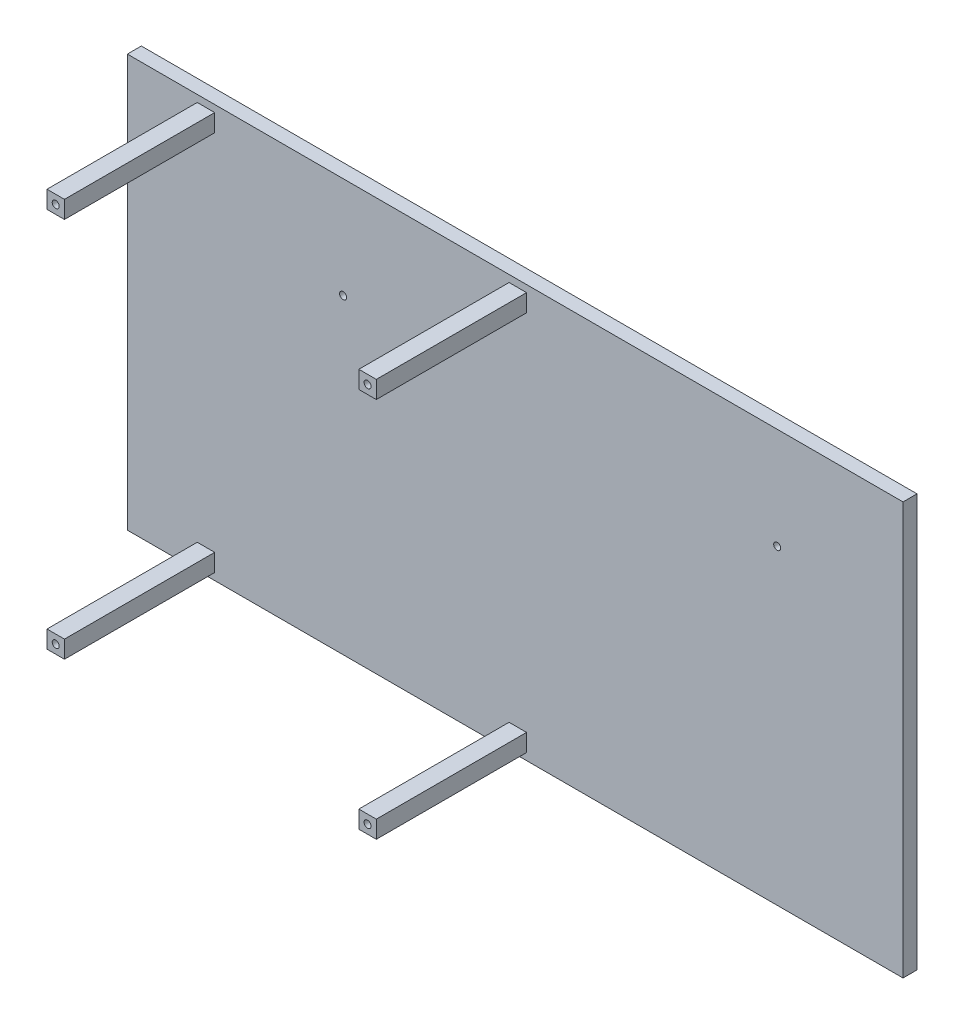
from build123d import *

# Parameters (mm, degrees)
SKETCH1_W            = 200
SKETCH1_H            = 150
BOSS_EXTRUDE1_DEPTH  = 4
SKETCH2_W            = 4
SKETCH2_H            = 150
BOSS_EXTRUDE2_DEPTH  = 50
SKETCH3_R            = 1
CUT_EXTRUDE1_DEPTH   = 21
SKETCH4_R            = 1
CUT_EXTRUDE2_DEPTH   = 21
SKETCH5_R            = 1
CUT_EXTRUDE3_DEPTH   = 21
SKETCH6_R            = 1
CUT_EXTRUDE4_DEPTH   = 5
SKETCH7_R            = 6.144102529
BOSS_EXTRUDE3_DEPTH  = 4
SKETCH8_W            = 5
SKETCH8_H            = 5
BOSS_EXTRUDE4_DEPTH  = 43
SKETCH9_W            = 5
SKETCH9_H            = 5
BOSS_EXTRUDE5_DEPTH  = 43
SKETCH10_W           = 5
SKETCH10_H           = 5
BOSS_EXTRUDE6_DEPTH  = 43
SKETCH11_W           = 30
SKETCH11_H           = 150
CUT_EXTRUDE5_DEPTH   = 10
SKETCH12_W           = 220
SKETCH12_H           = 24.5
CUT_EXTRUDE6_DEPTH   = 10
SKETCH13_W           = 40.875499452
SKETCH13_H           = 23.792139599
SKETCH13_W_2         = 30.776846646
SKETCH13_H_2         = 32.17722556
CUT_EXTRUDE7_DEPTH   = 43
SKETCH14_W           = 220
SKETCH14_H           = 7.5
CUT_EXTRUDE8_DEPTH   = 10
SKETCH15_W           = 2
SKETCH15_H           = 118
BOSS_EXTRUDE7_DEPTH  = 47
SKETCH17_W           = 7
SKETCH17_H           = 7
BOSS_EXTRUDE8_DEPTH  = 10
SKETCH18_R           = 2.5
CUT_EXTRUDE9_DEPTH   = 9
SKETCH19_R           = 1
BOSS_EXTRUDE9_DEPTH  = 9
FILLET1_R            = 1
SKETCH20_W           = 7.2
SKETCH20_H           = 14.5
BOSS_EXTRUDE10_DEPTH = 10
SKETCH21_W           = 4.962321038
SKETCH21_H           = 12.373907849
CUT_EXTRUDE10_DEPTH  = 9
SKETCH22_W           = 0.777431132
SKETCH22_H           = 9.230205418
BOSS_EXTRUDE11_DEPTH = 8
SKETCH23_W           = 0.590875022
SKETCH23_H           = 0.8
SKETCH23_H_2         = 0.836280482
SKETCH23_H_3         = 0.787087512
BOSS_EXTRUDE12_DEPTH = 7
SKETCH24_W           = 5
SKETCH24_H           = 5
BOSS_EXTRUDE13_DEPTH = 43
SKETCH25_W           = 5
SKETCH25_H           = 5
BOSS_EXTRUDE14_DEPTH = 43
CUT_EXTRUDE11_START  = -43
SKETCH26_W           = 5
SKETCH26_H           = 5
CUT_EXTRUDE11_DEPTH  = 43
SKETCH27_W           = 5
SKETCH27_H           = 5
BOSS_EXTRUDE15_DEPTH = 43
CUT_EXTRUDE12_START  = -43
SKETCH28_W           = 5
SKETCH28_H           = 5
CUT_EXTRUDE12_DEPTH  = 43
SKETCH29_W           = 2
SKETCH29_H           = 66.409922273
BOSS_EXTRUDE16_DEPTH = 47
SKETCH30_W           = 8
SKETCH30_H           = 7
SKETCH30_H_2         = 14.5
CUT_EXTRUDE13_DEPTH  = 9.5
SKETCH31_W           = 5
SKETCH31_H           = 5
CUT_EXTRUDE14_DEPTH  = 43
SKETCH32_W           = 5
SKETCH32_H           = 5
BOSS_EXTRUDE17_DEPTH = 43
SKETCH35_W           = 5
SKETCH35_H           = 5
BOSS_EXTRUDE18_DEPTH = 43
SKETCH37_R           = 1
CUT_EXTRUDE16_DEPTH  = 3
CUT_EXTRUDE17_START  = -43
SKETCH38_W           = 2
SKETCH38_H           = 118
CUT_EXTRUDE17_DEPTH  = 43
SKETCH39_W           = 5
SKETCH39_H           = 5
BOSS_EXTRUDE19_DEPTH = 43
CUT_EXTRUDE18_START  = -43
SKETCH40_W           = 5
SKETCH40_H           = 5
CUT_EXTRUDE18_DEPTH  = 43
SKETCH41_R           = 1
CUT_EXTRUDE19_DEPTH  = 3
CUT_EXTRUDE20_START  = -43
SKETCH42_W           = 21.919538156
SKETCH42_H           = 26.204036761
CUT_EXTRUDE20_DEPTH  = 43
SKETCH43_W           = 59.077186418
SKETCH43_H           = 35.909235562
BOSS_EXTRUDE20_DEPTH = 4


with BuildPart() as part:
    # Sketch1 → Boss-Extrude1 (new body)
    with BuildSketch(Plane.XY):
        with Locations((0.223214286, -36.941964286)):
            Rectangle(SKETCH1_W, SKETCH1_H)
    extrude(amount=BOSS_EXTRUDE1_DEPTH)

    # Sketch2 → Boss-Extrude2 (add)
    with BuildSketch(Plane(origin=(100.223214286, 0, 0), x_dir=(0, 0, -1), z_dir=(1, 0, 0))):
        with Locations((-2, -36.941964286)):
            Rectangle(SKETCH2_W, SKETCH2_H)
    extrude(amount=BOSS_EXTRUDE2_DEPTH)

    # Sketch3 → Cut-Extrude1 (cut)
    with BuildSketch(Plane(origin=(0, 0, 0), x_dir=(-1, 0, 0), z_dir=(0, 0, -1))):
        with Locations((96.776785714, -77.941964286)):
            Circle(SKETCH3_R)
    extrude(amount=-CUT_EXTRUDE1_DEPTH, mode=Mode.SUBTRACT)

    # Sketch4 → Cut-Extrude2 (cut)
    with BuildSketch(Plane(origin=(0, 0, 0), x_dir=(-1, 0, 0), z_dir=(0, 0, -1))):
        with Locations((-147.223214286, -77.941964286)):
            Circle(SKETCH4_R)
    extrude(amount=-CUT_EXTRUDE2_DEPTH, mode=Mode.SUBTRACT)

    # Sketch5 → Cut-Extrude3 (cut)
    with BuildSketch(Plane(origin=(0, 0, 0), x_dir=(-1, 0, 0), z_dir=(0, 0, -1))):
        with Locations((-99.423214286, -77.941964286)):
            Circle(SKETCH5_R)
    extrude(amount=-CUT_EXTRUDE3_DEPTH, mode=Mode.SUBTRACT)

    # Sketch6 → Cut-Extrude4 (cut, through all)
    with BuildSketch(Plane.XY.offset(4)):
        with Locations((114.203214286, -15.441964286)):
            Circle(SKETCH6_R)
        with Locations((-10.026785714, -15.441964286)):
            Circle(SKETCH6_R)
    extrude(amount=-CUT_EXTRUDE4_DEPTH, mode=Mode.SUBTRACT)

    # Sketch7 → Boss-Extrude3 (add)
    with BuildSketch(Plane(origin=(0, 0, 0), x_dir=(-1, 0, 0), z_dir=(0, 0, -1))):
        with Locations((93.632683185, -80.249228077)):
            Circle(SKETCH7_R)
    extrude(amount=-BOSS_EXTRUDE3_DEPTH)

    # Sketch8 → Boss-Extrude4 (add)
    with BuildSketch(Plane.XY.offset(4)):
        with Locations((-10.026785714, 9.058035714)):
            Rectangle(SKETCH8_W, SKETCH8_H)
        with Locations((113.836980241, 9.058035714)):
            Rectangle(SKETCH8_W, SKETCH8_H)
    extrude(amount=BOSS_EXTRUDE4_DEPTH)

    # Sketch9 → Boss-Extrude5 (add)
    with BuildSketch(Plane.XY.offset(4)):
        with Locations((39.973214286, 9.058035714)):
            Rectangle(SKETCH9_W, SKETCH9_H)
    extrude(amount=BOSS_EXTRUDE5_DEPTH)

    # Sketch10 → Boss-Extrude6 (add)
    with BuildSketch(Plane.XY.offset(4)):
        with Locations((-65.026785714, 9.058035714)):
            Rectangle(SKETCH10_W, SKETCH10_H)
    extrude(amount=BOSS_EXTRUDE6_DEPTH)

    # Sketch11 → Cut-Extrude5 (cut)
    with BuildSketch(Plane.XY.offset(4)):
        with Locations((-84.776785714, -36.941964286)):
            Rectangle(SKETCH11_W, SKETCH11_H)
    extrude(amount=-CUT_EXTRUDE5_DEPTH, mode=Mode.SUBTRACT)

    # Sketch12 → Cut-Extrude6 (cut)
    with BuildSketch(Plane.XY.offset(4)):
        with Locations((40.223214286, 25.808035714)):
            Rectangle(SKETCH12_W, SKETCH12_H)
    extrude(amount=-CUT_EXTRUDE6_DEPTH, mode=Mode.SUBTRACT)

    # Sketch13 → Cut-Extrude7 (cut)
    with BuildSketch(Plane.XY.offset(47)):
        with Locations((121.493324961, 1.661965914)):
            Rectangle(SKETCH13_W, SKETCH13_H)
        with Locations((-5.461167455, 0)):
            Rectangle(SKETCH13_W_2, SKETCH13_H_2)
    extrude(amount=-CUT_EXTRUDE7_DEPTH, mode=Mode.SUBTRACT)

    # Sketch14 → Cut-Extrude8 (cut)
    with BuildSketch(Plane.XY.offset(4)):
        with Locations((40.223214286, -108.191964286)):
            Rectangle(SKETCH14_W, SKETCH14_H)
    extrude(amount=-CUT_EXTRUDE8_DEPTH, mode=Mode.SUBTRACT)

    # Sketch15 → Boss-Extrude7 (add)
    with BuildSketch(Plane(origin=(0, 0, 0), x_dir=(-1, 0, 0), z_dir=(0, 0, -1))):
        with Locations((70.776785714, -45.441964286)):
            Rectangle(SKETCH15_W, SKETCH15_H)
    extrude(amount=-BOSS_EXTRUDE7_DEPTH)

    # Sketch17 → Boss-Extrude8 (add)
    with BuildSketch(Plane.ZY.offset(71.776785714)):
        with Locations((10, -45.441964286)):
            Rectangle(SKETCH17_W, SKETCH17_H)
    extrude(amount=-BOSS_EXTRUDE8_DEPTH)

    # Sketch18 → Cut-Extrude9 (cut)
    with BuildSketch(Plane.ZY.offset(71.776785714)):
        with Locations((10, -45.441964286)):
            Circle(SKETCH18_R)
    extrude(amount=-CUT_EXTRUDE9_DEPTH, mode=Mode.SUBTRACT)

    # Sketch20 → Boss-Extrude10 (add)
    with BuildSketch(Plane.ZY.offset(71.776785714)):
        with Locations((9.71931332, -90.191964286)):
            Rectangle(SKETCH20_W, SKETCH20_H)
    extrude(amount=-BOSS_EXTRUDE10_DEPTH)

    # Sketch21 → Cut-Extrude10 (cut)
    with BuildSketch(Plane.ZY.offset(71.776785714)):
        with Locations((9.788933034, -90.191964286)):
            Rectangle(SKETCH21_W, SKETCH21_H)
    extrude(amount=-CUT_EXTRUDE10_DEPTH, mode=Mode.SUBTRACT)

    # Sketch22 → Boss-Extrude11 (add)
    with BuildSketch(Plane.ZY.offset(62.776785714)):
        with Locations((9.788933034, -90.191964286)):
            Rectangle(SKETCH22_W, SKETCH22_H)
    extrude(amount=BOSS_EXTRUDE11_DEPTH)

    # Sketch23 → Boss-Extrude12 (add)
    with BuildSketch(Plane.ZY.offset(62.776785714)):
        with Locations((10.473086111, -86.324413604)):
            Rectangle(SKETCH23_W, SKETCH23_H)
        with Locations((10.473086111, -88.407696998)):
            Rectangle(SKETCH23_W, SKETCH23_H_2)
        with Locations((10.473086111, -91.482257593)):
            Rectangle(SKETCH23_W, SKETCH23_H_3)
        with Locations((10.473086111, -93.720537707)):
            Rectangle(SKETCH23_W, SKETCH23_H_2)
    extrude(amount=BOSS_EXTRUDE12_DEPTH)

    # Sketch24 → Boss-Extrude13 (add)
    with BuildSketch(Plane.XY.offset(4)):
        with Locations((39.973214286, -39.941964286)):
            Rectangle(SKETCH24_W, SKETCH24_H)
    extrude(amount=BOSS_EXTRUDE13_DEPTH)

    # Sketch25 → Boss-Extrude14 (add)
    with BuildSketch(Plane.XY.offset(4)):
        with Locations((39.973214286, -65.941964286)):
            Rectangle(SKETCH25_W, SKETCH25_H)
        with Locations((-65.026785714, -65.941964286)):
            Rectangle(SKETCH25_W, SKETCH25_H)
    extrude(amount=BOSS_EXTRUDE14_DEPTH)

    # Sketch26 → Cut-Extrude11 (cut)
    with BuildSketch(Plane.XY.offset(47).offset(CUT_EXTRUDE11_START)):
        with Locations((39.973214286, -39.941964286)):
            Rectangle(SKETCH26_W, SKETCH26_H)
    extrude(amount=CUT_EXTRUDE11_DEPTH, mode=Mode.SUBTRACT)

    # Sketch27 → Boss-Extrude15 (add)
    with BuildSketch(Plane.XY.offset(4)):
        with Locations((39.973214286, -99.941964286)):
            Rectangle(SKETCH27_W, SKETCH27_H)
    extrude(amount=BOSS_EXTRUDE15_DEPTH)

    # Sketch28 → Cut-Extrude12 (cut)
    with BuildSketch(Plane.XY.offset(47).offset(CUT_EXTRUDE12_START)):
        with Locations((39.973214286, -65.941964286)):
            Rectangle(SKETCH28_W, SKETCH28_H)
    extrude(amount=CUT_EXTRUDE12_DEPTH, mode=Mode.SUBTRACT)



with BuildPart() as body_2:
    # Sketch19 → Boss-Extrude9 (new body)
    with BuildSketch(Plane.ZY.offset(62.776785714)):
        with Locations((10, -45.441964286)):
            Circle(SKETCH19_R)
    extrude(amount=BOSS_EXTRUDE9_DEPTH)

    # Fillet1
    fillet1_edges = [body_2.edges().sort_by_distance(p)[0] for p in [
        (-71.776785714, -45.441964286, 9),
    ]]
    fillet(fillet1_edges, radius=FILLET1_R)


with BuildPart() as part_1:
    add(part.part)

    add(body_2.part)  # Boss-Extrude16 merges body 2
    # Sketch29 → Boss-Extrude16 (add)
    with BuildSketch(Plane.XY.offset(47)):
        with Locations((-70.776785714, -71.237003149)):
            Rectangle(SKETCH29_W, SKETCH29_H)
    extrude(amount=-BOSS_EXTRUDE16_DEPTH)

    # Sketch30 → Cut-Extrude13 (cut)
    with BuildSketch(Plane.XY.offset(13.5)):
        with Locations((-65.776785714, -45.441964286)):
            Rectangle(SKETCH30_W, SKETCH30_H)
        with Locations((-65.776785714, -90.191964286)):
            Rectangle(SKETCH30_W, SKETCH30_H_2)
    extrude(amount=-CUT_EXTRUDE13_DEPTH, mode=Mode.SUBTRACT)

    # Sketch31 → Cut-Extrude14 (cut)
    with BuildSketch(Plane.XY.offset(47)):
        with Locations((-65.026785714, -65.941964286)):
            Rectangle(SKETCH31_W, SKETCH31_H)
    extrude(amount=-CUT_EXTRUDE14_DEPTH, mode=Mode.SUBTRACT)

    # Sketch32 → Boss-Extrude17 (add)
    with BuildSketch(Plane.XY.offset(4)):
        with Locations((-65.026785714, -99.941964286)):
            Rectangle(SKETCH32_W, SKETCH32_H)
    extrude(amount=BOSS_EXTRUDE17_DEPTH)

    # Sketch35 → Boss-Extrude18 (add)
    with BuildSketch(Plane.XY.offset(4)):
        with Locations((-12.526785714, -39.941964286)):
            Rectangle(SKETCH35_W, SKETCH35_H)
    extrude(amount=BOSS_EXTRUDE18_DEPTH)

    # Sketch37 → Cut-Extrude16 (cut)
    with BuildSketch(Plane.XY.offset(47)):
        with Locations((39.973214286, 9.058035714)):
            Circle(SKETCH37_R)
        with Locations((39.973214286, -99.941964286)):
            Circle(SKETCH37_R)
        with Locations((-65.026785714, -99.941964286)):
            Circle(SKETCH37_R)
        with Locations((-65.026785714, 9.058035714)):
            Circle(SKETCH37_R)
        with Locations((-12.526785714, -39.941964286)):
            Circle(SKETCH37_R)
    extrude(amount=-CUT_EXTRUDE16_DEPTH, mode=Mode.SUBTRACT)

    # Sketch38 → Cut-Extrude17 (cut)
    with BuildSketch(Plane.XY.offset(47).offset(CUT_EXTRUDE17_START)):
        with Locations((-70.776785714, -45.441964286)):
            Rectangle(SKETCH38_W, SKETCH38_H)
    extrude(amount=CUT_EXTRUDE17_DEPTH, mode=Mode.SUBTRACT)

    # Sketch39 → Boss-Extrude19 (add)
    with BuildSketch(Plane.XY.offset(4)):
        with Locations((-49.276785714, 9.058035714)):
            Rectangle(SKETCH39_W, SKETCH39_H)
        with Locations((-49.276785714, -99.941964286)):
            Rectangle(SKETCH39_W, SKETCH39_H)
    extrude(amount=BOSS_EXTRUDE19_DEPTH)

    # Sketch40 → Cut-Extrude18 (cut)
    with BuildSketch(Plane.XY.offset(47).offset(CUT_EXTRUDE18_START)):
        with Locations((-65.026785714, 9.058035714)):
            Rectangle(SKETCH40_W, SKETCH40_H)
        with Locations((-65.026785714, -99.941964286)):
            Rectangle(SKETCH40_W, SKETCH40_H)
    extrude(amount=CUT_EXTRUDE18_DEPTH, mode=Mode.SUBTRACT)

    # Sketch41 → Cut-Extrude19 (cut)
    with BuildSketch(Plane.XY.offset(47)):
        with Locations((-49.276785714, 9.058035714)):
            Circle(SKETCH41_R)
        with Locations((-49.276785714, -99.941964286)):
            Circle(SKETCH41_R)
    extrude(amount=-CUT_EXTRUDE19_DEPTH, mode=Mode.SUBTRACT)

    # Sketch42 → Cut-Extrude20 (cut)
    with BuildSketch(Plane.XY.offset(47).offset(CUT_EXTRUDE20_START)):
        with Locations((-10.959769078, -42.894349601)):
            Rectangle(SKETCH42_W, SKETCH42_H)
    extrude(amount=CUT_EXTRUDE20_DEPTH, mode=Mode.SUBTRACT)

    # Sketch43 → Boss-Extrude20 (add)
    with BuildSketch(Plane.XY.offset(4)):
        with Locations((120.684621077, -77.590435312)):
            Rectangle(SKETCH43_W, SKETCH43_H)
    extrude(amount=-BOSS_EXTRUDE20_DEPTH)


solid = part_1.part
